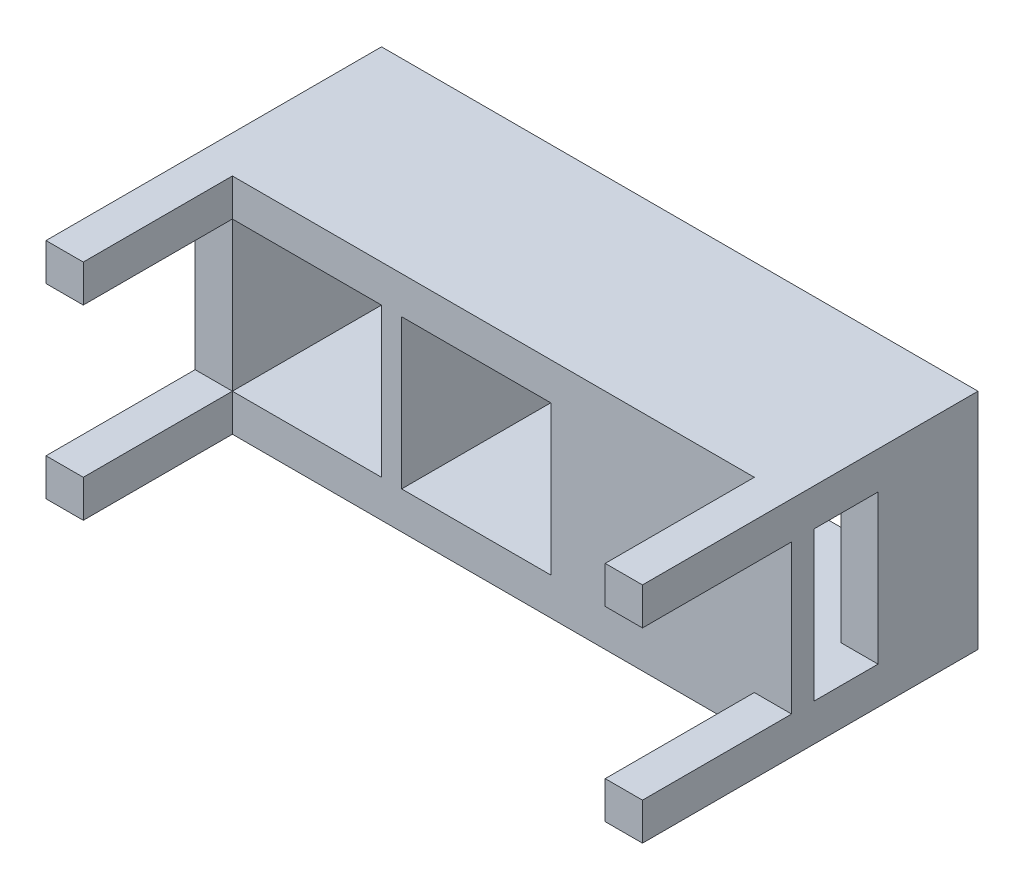
from build123d import *

# Parameters (mm, degrees)
SKETCH2_W            = 800
SKETCH2_H            = 300
BOSS_EXTRUDE1_DEPTH  = 100
SKETCH3_W            = 50
SKETCH3_H            = 50
BOSS_EXTRUDE2_DEPTH  = 200
SKETCH4_W            = 800
SKETCH4_H            = 300
SKETCH4_W_2          = 700
SKETCH4_H_2          = 200
BOSS_EXTRUDE3_DEPTH  = 150
SKETCH5_W            = 85.954447183
SKETCH5_H            = 200
CUT_EXTRUDE1_DEPTH   = 750
SKETCH6_W            = 7
SKETCH6_H            = 200
BOSS_EXTRUDE5_DEPTH  = 185
SKETCH9_W            = 7
SKETCH9_H            = 192.990182273
BOSS_EXTRUDE6_DEPTH  = 160
SKETCH12_W           = 200
SKETCH12_H           = 200
CUT_EXTRUDE4_DEPTH   = 111
SKETCH14_W           = 6.809905138
SKETCH14_H           = 7.009817727
BOSS_EXTRUDE9_DEPTH  = 160
BOSS_EXTRUDE10_DEPTH = 7
F_3DSKETCH2_R        = 2.5
CUT_EXTRUDE5_DEPTH   = 263.5


with BuildPart() as part:
    # Sketch2 → Boss-Extrude1 (new body)
    with BuildSketch(Plane.XY):
        with Locations((52.951699463, -18.694096601)):
            Rectangle(SKETCH2_W, SKETCH2_H)
    extrude(amount=BOSS_EXTRUDE1_DEPTH)

    # Sketch3 → Boss-Extrude2 (add)
    with BuildSketch(Plane.XY.offset(100)):
        with Locations((-322.048300537, 106.305903399)):
            Rectangle(SKETCH3_W, SKETCH3_H)
        with Locations((-322.048300537, -143.694096601)):
            Rectangle(SKETCH3_W, SKETCH3_H)
        with Locations((427.951699463, 106.305903399)):
            Rectangle(SKETCH3_W, SKETCH3_H)
        with Locations((427.951699463, -143.694096601)):
            Rectangle(SKETCH3_W, SKETCH3_H)
    extrude(amount=BOSS_EXTRUDE2_DEPTH)

    # Sketch4 → Boss-Extrude3 (add)
    with BuildSketch(Plane(origin=(0, 0, 0), x_dir=(-1, 0, 0), z_dir=(0, 0, -1))):
        with Locations((-52.951699463, -18.694096601)):
            Rectangle(SKETCH4_W, SKETCH4_H)
        with Locations((-52.951699463, -18.694096601)):
            Rectangle(SKETCH4_W_2, SKETCH4_H_2, mode=Mode.SUBTRACT)
    extrude(amount=BOSS_EXTRUDE3_DEPTH)

    # Sketch5 → Cut-Extrude1 (cut)
    with BuildSketch(Plane(origin=(452.951699463, 0, 0), x_dir=(0, 0, -1), z_dir=(1, 0, 0))):
        with Locations((-27.022776409, -18.694096601)):
            Rectangle(SKETCH5_W, SKETCH5_H)
    extrude(amount=-CUT_EXTRUDE1_DEPTH, mode=Mode.SUBTRACT)

    # Sketch6 → Boss-Extrude5 (add)
    with BuildSketch(Plane(origin=(0, 0, 70), x_dir=(-1, 0, 0), z_dir=(0, 0, -1))):
        with Locations((73.548300537, -18.694096601)):
            Rectangle(SKETCH6_W, SKETCH6_H)
    extrude(amount=BOSS_EXTRUDE5_DEPTH)

    # Sketch9 → Boss-Extrude6 (add)
    with BuildSketch(Plane(origin=(0, 0, 70), x_dir=(-1, 0, 0), z_dir=(0, 0, -1))):
        with Locations((-153.451699463, -15.189187737)):
            Rectangle(SKETCH9_W, SKETCH9_H)
    extrude(amount=BOSS_EXTRUDE6_DEPTH)

    # Sketch12 → Cut-Extrude4 (cut)
    with BuildSketch(Plane(origin=(0, 0, 70), x_dir=(-1, 0, 0), z_dir=(0, 0, -1))):
        with Locations((197.048300537, -18.694096601)):
            Rectangle(SKETCH12_W, SKETCH12_H)
        with Locations((-29.951699463, -18.694096601)):
            Rectangle(SKETCH12_W, SKETCH12_H)
    extrude(amount=-CUT_EXTRUDE4_DEPTH, mode=Mode.SUBTRACT)

    # Sketch14 → Boss-Extrude9 (add)
    with BuildSketch(Plane(origin=(0, 0, 70), x_dir=(-1, 0, 0), z_dir=(0, 0, -1))):
        with Locations((-153.546746894, -115.189187738)):
            Rectangle(SKETCH14_W, SKETCH14_H)
    extrude(amount=BOSS_EXTRUDE9_DEPTH)

    # 3DSketch1 → Boss-Extrude10 (add)
    with BuildSketch(Plane(origin=(-297.048300537, 81.305903399, -150), x_dir=(-0.033314830232638246, -0.9994449069791543, 0), z_dir=(0, 0, -1))):
        Polygon((0, 0), (0.233203812, 6.996114349), (-9.761245258, 7.329262651), (-9.99444907, 0.333148302), align=None)
        Polygon((199.888981396, -6.662966047), (200.122185207, 0.333148302), (210.116634277, 0), (209.883430466, -6.996114349), align=None)
    extrude(amount=BOSS_EXTRUDE10_DEPTH)

    # 3DSketch2 → Cut-Extrude5 (cut, symmetric)
    with BuildSketch(Plane(origin=(-297.048300537, -128.694096601, -157), x_dir=(-0.7071067811865476, 0, 0.7071067811865476), z_dir=(0, -1, 0))):
        with Locations(Location((4.949747468, 0, 0), (0, 0, 135))):
            Circle(F_3DSKETCH2_R)
    extrude(amount=CUT_EXTRUDE5_DEPTH, both=True, mode=Mode.SUBTRACT)


solid = part.part
